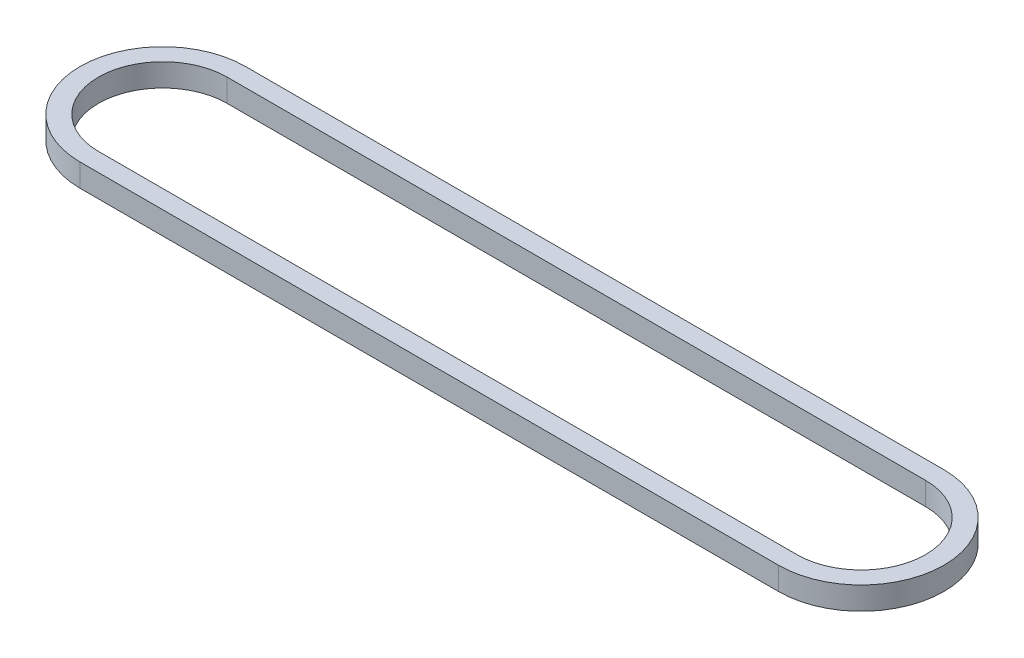
from build123d import *

# Parameters (mm, degrees)
BOSS_EXTRUDE1_DEPTH = 7.874


with BuildPart() as part:
    # Sketch1 → Boss-Extrude1 (new body)
    with BuildSketch(Plane(origin=(0, 0, 0), x_dir=(1, 0, 0), z_dir=(0, 1, 0))):
        with BuildLine():
            Line((0, 28.575), (241.3, 28.575))
            ThreePointArc((241.3, 28.575), (269.875, 0), (241.3, -28.575))
            Line((241.3, -28.575), (0, -28.575))
            ThreePointArc((0, -28.575), (-28.575, 0), (0, 28.575))
        make_face()
        with BuildLine():
            Line((0, 22.225), (241.3, 22.225))
            ThreePointArc((241.3, 22.225), (263.525, 0), (241.3, -22.225))
            Line((241.3, -22.225), (0, -22.225))
            ThreePointArc((0, -22.225), (-22.225, 0), (0, 22.225))
        make_face(mode=Mode.SUBTRACT)
    extrude(amount=BOSS_EXTRUDE1_DEPTH)


solid = part.part
